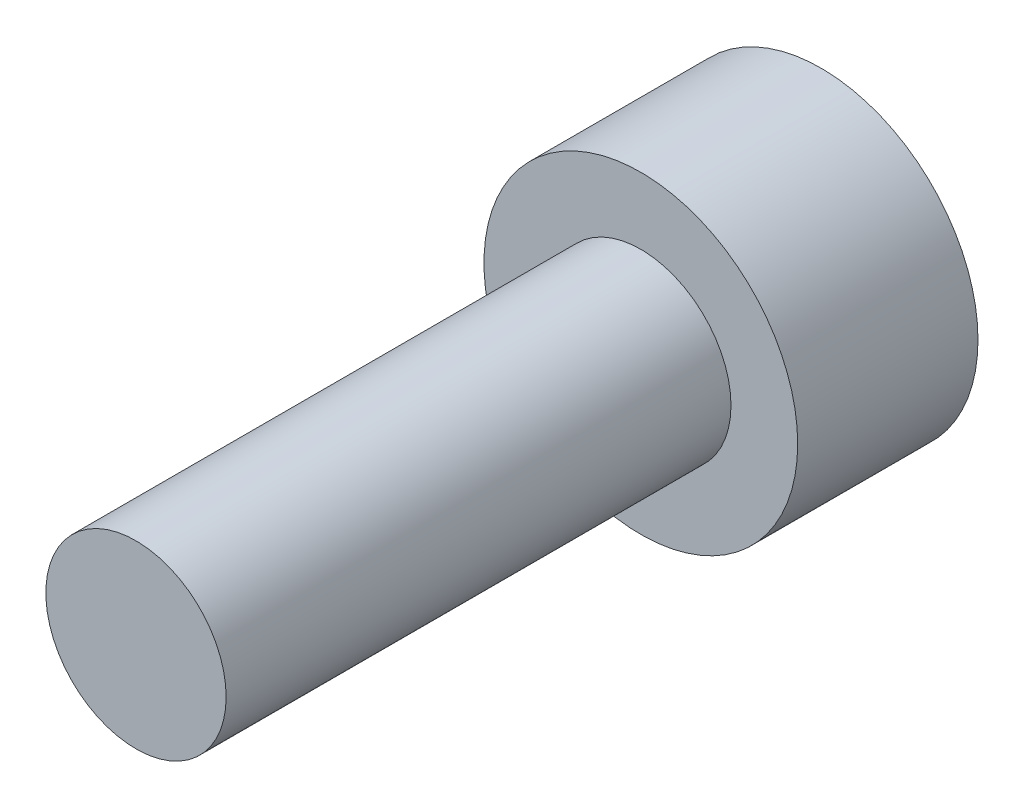
from build123d import *

# Parameters (mm, degrees)
SKETCH_1_R      = 4.35
EXTRUDE_1_DEPTH = 5
SKETCH_2_R      = 2.5
EXTRUDE_2_DEPTH = 14


with BuildPart() as part:
    # 草图1 → 凸台-拉伸1 (new body)
    with BuildSketch(Plane.XY):
        Circle(SKETCH_1_R)
    extrude(amount=EXTRUDE_1_DEPTH)

    # 草图2 → 凸台-拉伸2 (add)
    with BuildSketch(Plane.XY.offset(5)):
        Circle(SKETCH_2_R)
    extrude(amount=EXTRUDE_2_DEPTH)


solid = part.part
